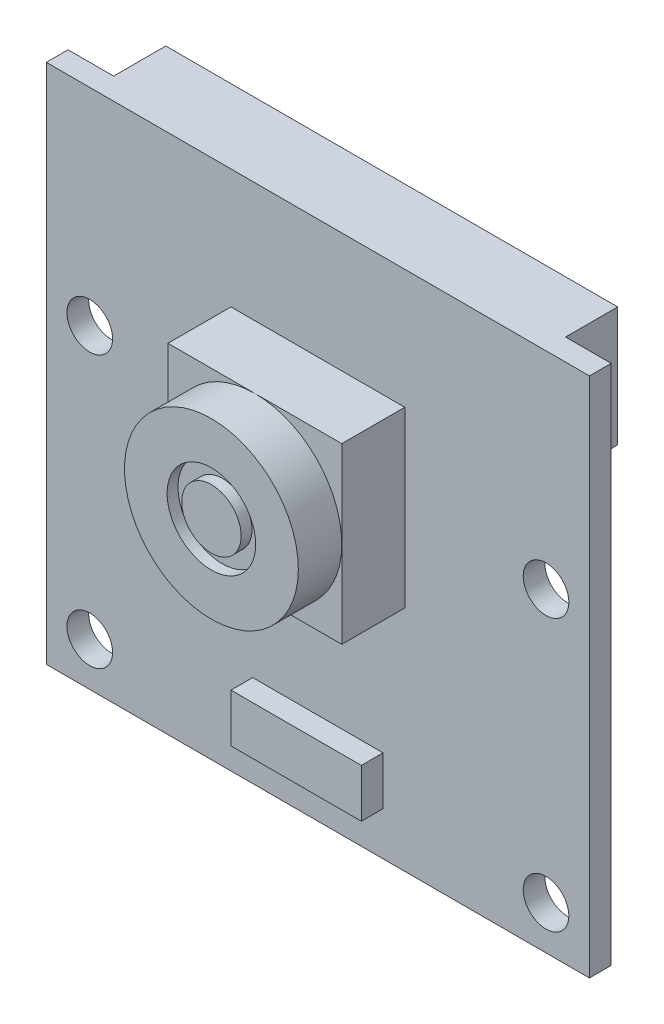
from build123d import *

# Parameters (mm, degrees)
SKETCH1_W           = 25
SKETCH1_H           = 24
SKETCH1_R           = 1.05
BOSS_EXTRUDE1_DEPTH = 1
SKETCH2_W           = 20.8
SKETCH2_H           = 5.5
BOSS_EXTRUDE2_DEPTH = 2.4
SKETCH3_W           = 8
SKETCH3_H           = 8
BOSS_EXTRUDE3_DEPTH = 4.9
CUT_EXTRUDE3_DEPTH  = 2
SKETCH7_R           = 2.038197989
SKETCH7_R_2         = 1.367783091
CUT_EXTRUDE4_DEPTH  = 0.5
SKETCH8_W           = 6
SKETCH8_H           = 2.224607268
BOSS_EXTRUDE4_DEPTH = 1


with BuildPart() as part:
    # Sketch1 → Boss-Extrude1 (new body)
    with BuildSketch(Plane.XY):
        Rectangle(SKETCH1_W, SKETCH1_H)
        with Locations((-10.5, 2.5)):
            Circle(SKETCH1_R, mode=Mode.SUBTRACT)
        with Locations((-10.5, -10)):
            Circle(SKETCH1_R, mode=Mode.SUBTRACT)
        with Locations((10.5, -10)):
            Circle(SKETCH1_R, mode=Mode.SUBTRACT)
        with Locations((10.5, 2.5)):
            Circle(SKETCH1_R, mode=Mode.SUBTRACT)
    extrude(amount=BOSS_EXTRUDE1_DEPTH)

    # Sketch2 → Boss-Extrude2 (add)
    with BuildSketch(Plane(origin=(0, 0, 0), x_dir=(-1, 0, 0), z_dir=(0, 0, -1))):
        with Locations((0, 9.25)):
            Rectangle(SKETCH2_W, SKETCH2_H)
    extrude(amount=BOSS_EXTRUDE2_DEPTH)

    # Sketch3 → Boss-Extrude3 (add)
    with BuildSketch(Plane.XY.offset(1)):
        with Locations((0, 2.5)):
            Rectangle(SKETCH3_W, SKETCH3_H)
    extrude(amount=BOSS_EXTRUDE3_DEPTH)

    # Sketch6 → Cut-Extrude3 (cut)
    with BuildSketch(Plane.XY.offset(5.9)):
        with BuildLine():
            Line((-4, 6.5), (-4, 2.499999997))
            ThreePointArc((-4, 2.499999997), (-2.828427126, 5.328427124), (0, 6.5))
            Line((0, 6.5), (-4, 6.5))
        make_face()
        with BuildLine():
            ThreePointArc((0, 6.5), (2.828427125, 5.328427125), (4, 2.5))
            Line((4, 2.5), (4, 6.5))
            Line((4, 6.5), (0, 6.5))
        make_face()
        with BuildLine():
            ThreePointArc((4, 2.5), (2.828427125, -0.328427125), (0, -1.5))
            Line((0, -1.5), (4, -1.5))
            Line((4, -1.5), (4, 2.5))
        make_face()
        with BuildLine():
            Line((-4, 2.499999997), (-4, -1.5))
            Line((-4, -1.5), (0, -1.5))
            ThreePointArc((0, -1.5), (-2.828427124, -0.328427126), (-4, 2.499999997))
        make_face()
    extrude(amount=-CUT_EXTRUDE3_DEPTH, mode=Mode.SUBTRACT)

    # Sketch7 → Cut-Extrude4 (cut)
    with BuildSketch(Plane.XY.offset(5.9)):
        with Locations((0, 2.5)):
            Circle(SKETCH7_R)
        with Locations((0, 2.5)):
            Circle(SKETCH7_R_2, mode=Mode.SUBTRACT)
    extrude(amount=-CUT_EXTRUDE4_DEPTH, mode=Mode.SUBTRACT)

    # Sketch8 → Boss-Extrude4 (add)
    with BuildSketch(Plane.XY.offset(1)):
        with Locations((0, -8.887696366)):
            Rectangle(SKETCH8_W, SKETCH8_H)
    extrude(amount=BOSS_EXTRUDE4_DEPTH)


solid = part.part
